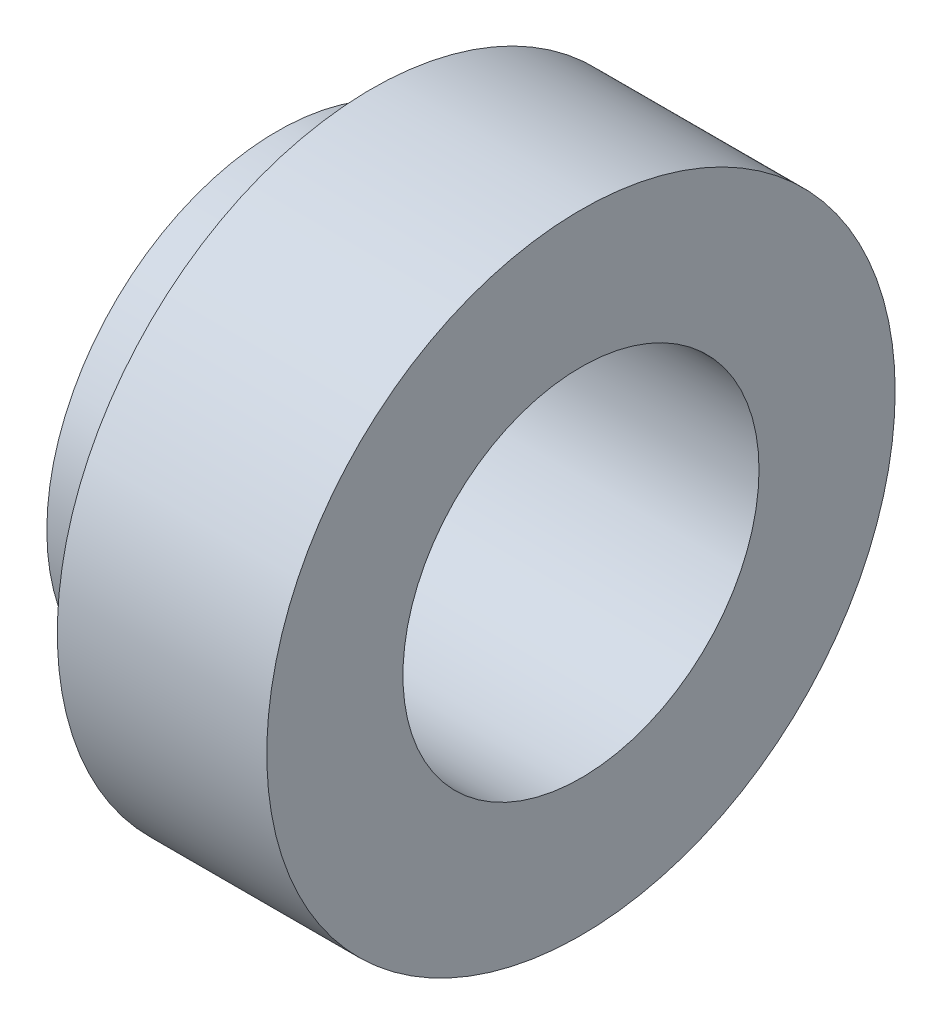
from build123d import *


with BuildPart() as part:
    # Sketch1 → Revolve1 (revolve)
    with BuildSketch(Plane.XY):
        Polygon((0, 11), (0, 8.5), (14.5, 8.5), (14.5, 15), (4.5, 15), (4.5, 11), align=None)
    revolve(axis=Axis((14.5, 0, 0), (-1, 0, 0)))


solid = part.part
